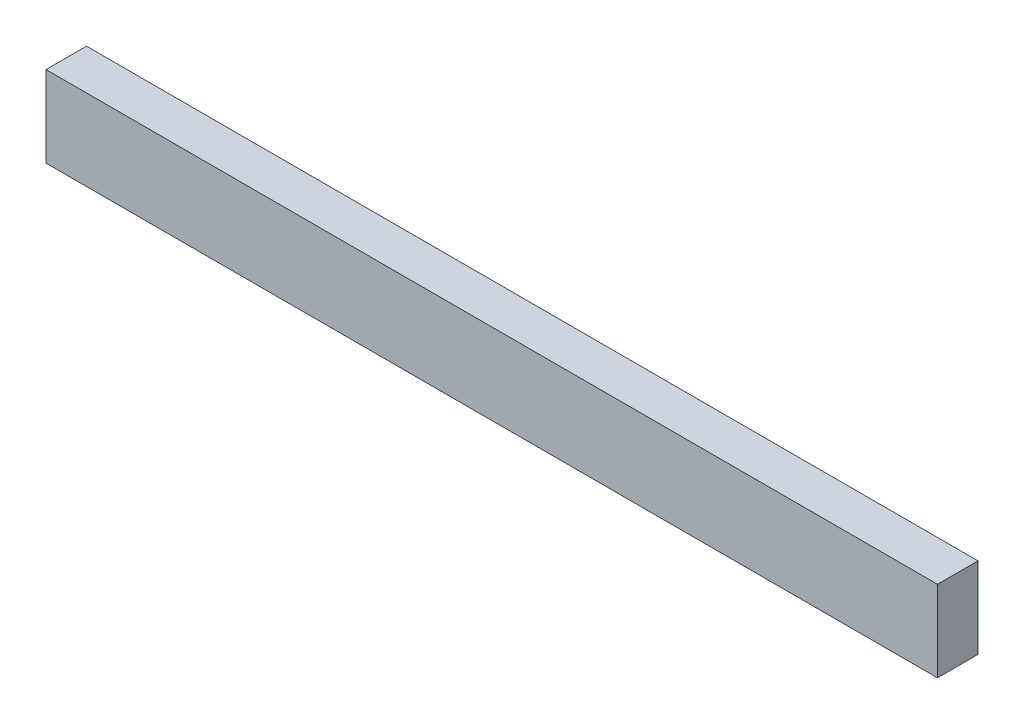
from build123d import *

# Parameters (mm, degrees)
SKETCH1_W           = 220
SKETCH1_H           = 20
BOSS_EXTRUDE1_DEPTH = 10


with BuildPart() as part:
    # Sketch1 → Boss-Extrude1 (new body)
    with BuildSketch(Plane.XY):
        Rectangle(SKETCH1_W, SKETCH1_H)
    extrude(amount=BOSS_EXTRUDE1_DEPTH)


solid = part.part
